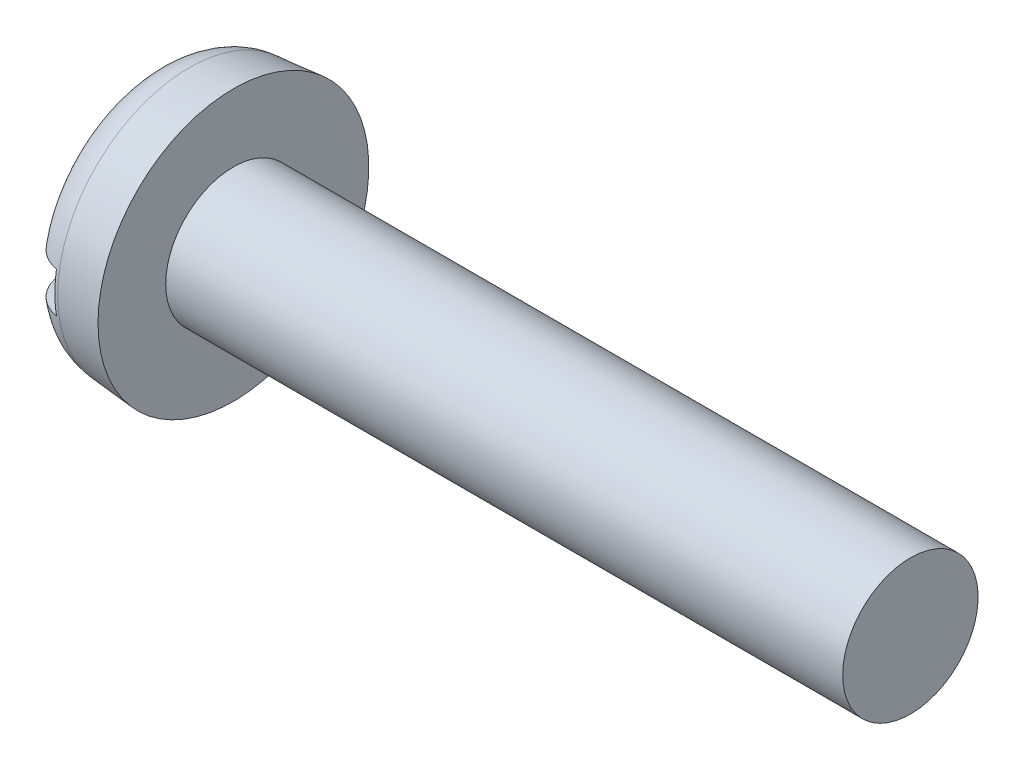
from build123d import *

# Parameters (mm, degrees)
FILLET2_R  = 1.2
SKETCH2_W  = 8
SKETCH2_H  = 1.2
SLOT_DEPTH = 1


with BuildPart() as part:
    # BodySke → Base-Revolve (revolve)
    with BuildSketch(Plane.XY):
        Polygon((2.4, 2), (2.4, 4), (0, 3.790027208), (0, 0), (22.4, 0), (22.4, 2), align=None)
    revolve(axis=Axis((-25.4, 0, 0), (1, 0, 0)))

    # Fillet2
    fillet2_edges = [part.edges().sort_by_distance(p)[0] for p in [
        (0, -3.790027208, 0),
    ]]
    fillet(fillet2_edges, radius=FILLET2_R)

    # Sketch2 → Slot (cut)
    with BuildSketch(Plane(origin=(0, 0, 0), x_dir=(0, 0, -1), z_dir=(1, 0, 0))):
        Rectangle(SKETCH2_W, SKETCH2_H)
    extrude(amount=SLOT_DEPTH, mode=Mode.SUBTRACT)


solid = part.part
